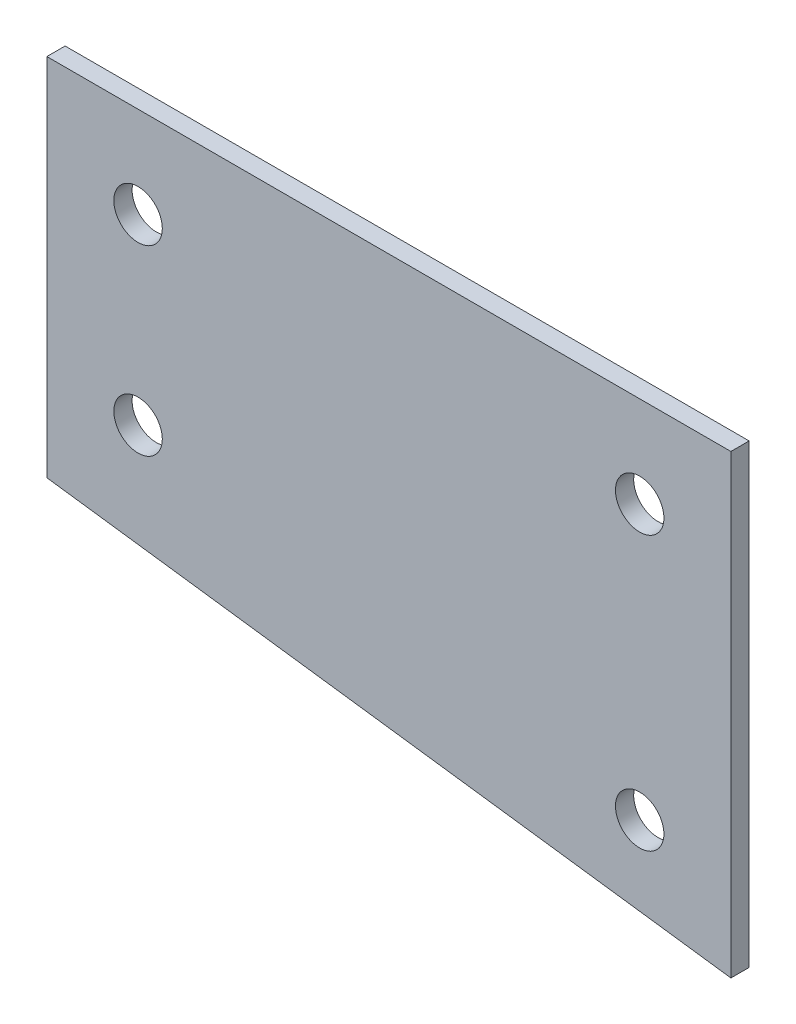
from build123d import *

# Parameters (mm, degrees)
BOSS_EXTRUDE3_DEPTH              = 1.27
SKETCH4_W                        = 107.901987654
SKETCH4_H                        = 12.7
CUT_EXTRUDE1_DEPTH               = 1
CUT_EXTRUDE1_DEPTH_BACK          = 3.54
F_17_64_0_26563_DIAMETER_HOLE1_D = 6.747002


with BuildPart() as part:
    # Sketch2 → Boss-Extrude3 (new body, symmetric)
    with BuildSketch(Plane.XY):
        Polygon((-95.25, -25.4), (-95.25, 25.4), (0, 38.1), (0, -38.1), align=None)
    extrude(amount=BOSS_EXTRUDE3_DEPTH, both=True)

    # Sketch4 → Cut-Extrude1 (cut, two sides)
    with BuildSketch(Plane.XY.offset(1.27)) as cut_extrude1_sk:
        with Locations((-53.950993827, 31.75)):
            Rectangle(SKETCH4_W, SKETCH4_H)
    extrude(amount=CUT_EXTRUDE1_DEPTH, mode=Mode.SUBTRACT)
    extrude(cut_extrude1_sk.sketch, amount=-CUT_EXTRUDE1_DEPTH_BACK, mode=Mode.SUBTRACT)

    # 17/64 (0.26563) Diameter Hole1 (through all)
    with Locations(Plane.XY.offset(1.27)):
        with Locations((-82.55, 12.7), (-82.55, -12.7), (-12.7, -25.4), (-12.7, 12.7)):
            Hole(F_17_64_0_26563_DIAMETER_HOLE1_D / 2)


solid = part.part
